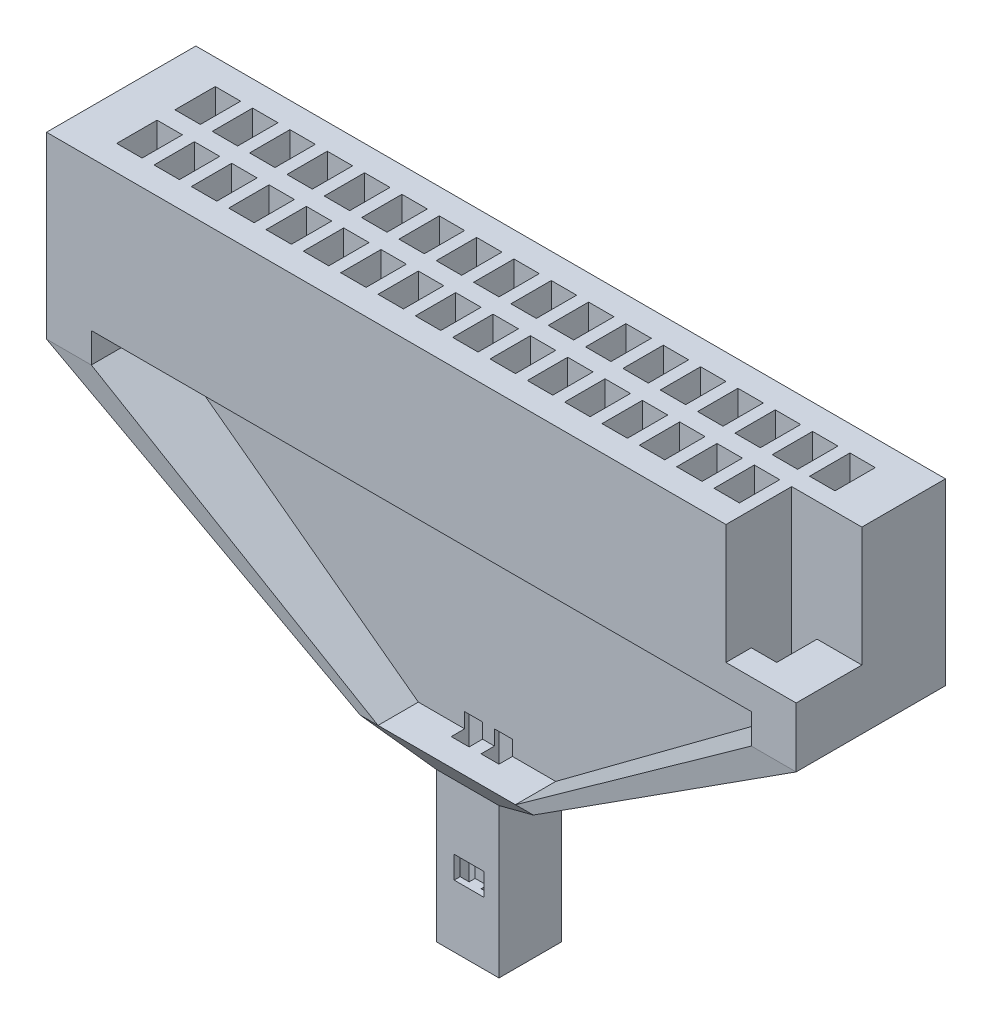
from build123d import *

# Parameters (mm, degrees)
MAIN_BLOCK_W        = 12.7508
MAIN_BLOCK_H        = 2.54
BOSS_EXTRUDE1_DEPTH = 2.54
TOP_HOLES_W         = 0.4318
TOP_HOLES_H         = 0.6858
CUT_EXTRUDE1_DEPTH  = 2.54
SKETCH8_W           = 0.762
SKETCH8_H           = 2.54
BOSS_EXTRUDE3_DEPTH = 0.508
SKETCH10_W          = 0.762
SKETCH10_H          = 2.54
BOSS_EXTRUDE2_DEPTH = 0.508
SKETCH7_W           = 0.3048
SKETCH7_H           = 1.77800034
SKETCH5_W           = 11.226700613
SKETCH5_H           = 0.3048
BOSS_EXTRUDE5_DEPTH = 0.508
SKETCH6_W           = 2.336782461
SKETCH6_H           = 0.3048
SKETCH12_W          = 2.9464
SKETCH12_H          = 1.77800034
SKETCH13_W          = 1.0668
SKETCH13_H          = 1.0668
SKETCH13_3_W        = 1.0668
SKETCH13_3_H        = 1.0668
BOSS_EXTRUDE6_DEPTH = 2.54
SKETCH14_W          = 0.3048
SKETCH14_H          = 0.3048
CUT_EXTRUDE2_DEPTH  = 3.302
SKETCH15_W          = 0.508
SKETCH15_H          = 0.381
CUT_EXTRUDE3_DEPTH  = 0.2032
SKETCH16_W          = 0.508
SKETCH16_H          = 0.381
CUT_EXTRUDE4_DEPTH  = 0.2032
SKETCH17_W          = 1.1938
SKETCH17_H          = 1.1176
CUT_EXTRUDE5_DEPTH  = 2.032


with BuildPart() as part:
    # main_block → Boss-Extrude1 (new body)
    with BuildSketch(Plane(origin=(0, 0, 0), x_dir=(1, 0, 0), z_dir=(0, 1, 0))):
        with Locations((0.756592766, -0.05080017)):
            Rectangle(MAIN_BLOCK_W, MAIN_BLOCK_H)
    extrude(amount=-BOSS_EXTRUDE1_DEPTH)

    # top_holes → Cut-Extrude1 (cut)
    with BuildSketch(Plane(origin=(0, 0, 0), x_dir=(1, 0, 0), z_dir=(0, 1, 0))):
        with Locations((6.154092766, 0.44449983)):
            Rectangle(TOP_HOLES_W, TOP_HOLES_H)
        with Locations((5.519098613, 0.44449983)):
            Rectangle(TOP_HOLES_W, TOP_HOLES_H)
        with Locations((4.884104459, 0.44449983)):
            Rectangle(TOP_HOLES_W, TOP_HOLES_H)
        with Locations((4.249110305, 0.44449983)):
            Rectangle(TOP_HOLES_W, TOP_HOLES_H)
        with Locations((3.614116151, 0.44449983)):
            Rectangle(TOP_HOLES_W, TOP_HOLES_H)
        with Locations((2.979121998, 0.44449983)):
            Rectangle(TOP_HOLES_W, TOP_HOLES_H)
        with Locations((2.344127844, 0.44449983)):
            Rectangle(TOP_HOLES_W, TOP_HOLES_H)
        with Locations((1.70913369, 0.44449983)):
            Rectangle(TOP_HOLES_W, TOP_HOLES_H)
        with Locations((1.074139537, 0.44449983)):
            Rectangle(TOP_HOLES_W, TOP_HOLES_H)
        with Locations((0.439145383, 0.44449983)):
            Rectangle(TOP_HOLES_W, TOP_HOLES_H)
        with Locations((-0.195848771, 0.44449983)):
            Rectangle(TOP_HOLES_W, TOP_HOLES_H)
        with Locations((-0.830842925, 0.44449983)):
            Rectangle(TOP_HOLES_W, TOP_HOLES_H)
        with Locations((-1.465837078, 0.44449983)):
            Rectangle(TOP_HOLES_W, TOP_HOLES_H)
        with Locations((-2.100831232, 0.44449983)):
            Rectangle(TOP_HOLES_W, TOP_HOLES_H)
        with Locations((-2.735825386, 0.44449983)):
            Rectangle(TOP_HOLES_W, TOP_HOLES_H)
        with Locations((-3.370819539, 0.44449983)):
            Rectangle(TOP_HOLES_W, TOP_HOLES_H)
        with Locations((-4.005813693, 0.44449983)):
            Rectangle(TOP_HOLES_W, TOP_HOLES_H)
        with Locations((-4.640807847, 0.44449983)):
            Rectangle(TOP_HOLES_W, TOP_HOLES_H)
        with Locations((5.519098613, -0.54610017)):
            Rectangle(TOP_HOLES_W, TOP_HOLES_H)
        with Locations((4.884104459, -0.54610017)):
            Rectangle(TOP_HOLES_W, TOP_HOLES_H)
        with Locations((4.249110305, -0.54610017)):
            Rectangle(TOP_HOLES_W, TOP_HOLES_H)
        with Locations((3.614116151, -0.54610017)):
            Rectangle(TOP_HOLES_W, TOP_HOLES_H)
        with Locations((2.979121998, -0.54610017)):
            Rectangle(TOP_HOLES_W, TOP_HOLES_H)
        with Locations((2.344127844, -0.54610017)):
            Rectangle(TOP_HOLES_W, TOP_HOLES_H)
        with Locations((1.70913369, -0.54610017)):
            Rectangle(TOP_HOLES_W, TOP_HOLES_H)
        with Locations((1.074139537, -0.54610017)):
            Rectangle(TOP_HOLES_W, TOP_HOLES_H)
        with Locations((0.439145383, -0.54610017)):
            Rectangle(TOP_HOLES_W, TOP_HOLES_H)
        with Locations((-0.195848771, -0.54610017)):
            Rectangle(TOP_HOLES_W, TOP_HOLES_H)
        with Locations((-0.830842925, -0.54610017)):
            Rectangle(TOP_HOLES_W, TOP_HOLES_H)
        with Locations((-1.465837078, -0.54610017)):
            Rectangle(TOP_HOLES_W, TOP_HOLES_H)
        with Locations((-2.100831232, -0.54610017)):
            Rectangle(TOP_HOLES_W, TOP_HOLES_H)
        with Locations((-2.735825386, -0.54610017)):
            Rectangle(TOP_HOLES_W, TOP_HOLES_H)
        with Locations((-3.370819539, -0.54610017)):
            Rectangle(TOP_HOLES_W, TOP_HOLES_H)
        with Locations((-4.005813693, -0.54610017)):
            Rectangle(TOP_HOLES_W, TOP_HOLES_H)
        with Locations((-4.640807847, -0.54610017)):
            Rectangle(TOP_HOLES_W, TOP_HOLES_H)
        with Locations((6.154092766, -0.54610017)):
            Rectangle(TOP_HOLES_W, TOP_HOLES_H)
    extrude(amount=-CUT_EXTRUDE1_DEPTH, mode=Mode.SUBTRACT)

    # Sketch8 → Boss-Extrude3 (add)
    with BuildSketch(Plane.XZ.offset(2.54)):
        with Locations((-5.237707847, 0.05080017)):
            Rectangle(SKETCH8_W, SKETCH8_H)
    extrude(amount=BOSS_EXTRUDE3_DEPTH)

    # Sketch10 → Boss-Extrude2 (add)
    with BuildSketch(Plane.XZ.offset(2.54)):
        with Locations((6.750992766, 0.05080017)):
            Rectangle(SKETCH10_W, SKETCH10_H)
    extrude(amount=BOSS_EXTRUDE2_DEPTH)

    # Sketch9 → section 0 of loft4
    with BuildSketch(Plane(origin=(0, -6.35, 0), x_dir=(1, 0, 0), z_dir=(0, 1, 0)), mode=Mode.PRIVATE) as loft4_s0:
        Polygon((1.92503369, -0.88900017), (1.924934303, 0.88900017), (2.229734303, 0.889017208), (2.22983369, -0.888983133), align=None)
    # loft up to a face of the part (loft4)
    loft([loft4_s0.sketch, part.faces().sort_by_distance((6.750992766, -3.048, 0.05080017))[0]])

    # Sketch7 → section 0 of loft14
    with BuildSketch(Plane(origin=(0, -6.35, 0), x_dir=(1, 0, 0), z_dir=(0, 1, 0)), mode=Mode.PRIVATE) as loft14_s0:
        with Locations((-0.564148771, 0)):
            Rectangle(SKETCH7_W, SKETCH7_H)
    # loft up to a face of the part (loft14)
    loft([loft14_s0.sketch, part.faces().sort_by_distance((-5.237707847, -3.048, 0.05080017))[0]])

    # Sketch5 → Boss-Extrude5 (add)
    with BuildSketch(Plane.XZ.offset(2.54)):
        with Locations((0.75664246, 0.05080017)):
            Rectangle(SKETCH5_W, SKETCH5_H)
    extrude(amount=BOSS_EXTRUDE5_DEPTH)

    # Sketch6 → section 1 of loft15
    with BuildSketch(Plane(origin=(0, -6.35, 0), x_dir=(1, 0, 0), z_dir=(0, 1, 0)), mode=Mode.PRIVATE) as loft15_s1:
        with Locations((0.756642459, -0.05080017)):
            Rectangle(SKETCH6_W, SKETCH6_H)
    # loft from a face of the part (loft15)
    loft([part.faces().sort_by_distance((0.75664246, -3.048, 0.05080017))[0], loft15_s1.sketch])

    # Sketch12 → Loft16 section 0
    with BuildSketch(Plane(origin=(0, -6.35, 0), x_dir=(1, 0, 0), z_dir=(0, 1, 0))):
        with Locations((0.756651229, 0)):
            Rectangle(SKETCH12_W, SKETCH12_H)
    # Sketch13 → Loft16 section 1
    with BuildSketch(Plane(origin=(0, -6.858, 0), x_dir=(1, 0, 0), z_dir=(0, 1, 0))):
        with Locations((0.756592766, 0)):
            Rectangle(SKETCH13_W, SKETCH13_H)
    loft()

    # Sketch13_3 → Boss-Extrude6 (add)
    with BuildSketch(Plane(origin=(0, -6.858, 0), x_dir=(1, 0, 0), z_dir=(0, 1, 0))):
        with Locations((0.756592766, 0)):
            Rectangle(SKETCH13_3_W, SKETCH13_3_H)
    extrude(amount=-BOSS_EXTRUDE6_DEPTH)

    # Sketch14 → Cut-Extrude2 (cut)
    with BuildSketch(Plane.XZ.offset(9.398)):
        with Locations((0.527992766, -0.2286)):
            Rectangle(SKETCH14_W, SKETCH14_H)
        with Locations((1.035992766, -0.2286)):
            Rectangle(SKETCH14_W, SKETCH14_H)
        with Locations((1.035992766, 0.2794)):
            Rectangle(SKETCH14_W, SKETCH14_H)
        with Locations((0.527992766, 0.2794)):
            Rectangle(SKETCH14_W, SKETCH14_H)
    extrude(amount=-CUT_EXTRUDE2_DEPTH, mode=Mode.SUBTRACT)

    # Sketch15 → Cut-Extrude3 (cut)
    with BuildSketch(Plane.XY.offset(0.5334)):
        with Locations((0.781992766, -8.146813232)):
            Rectangle(SKETCH15_W, SKETCH15_H)
    extrude(amount=-CUT_EXTRUDE3_DEPTH, mode=Mode.SUBTRACT)

    # Sketch16 → Cut-Extrude4 (cut)
    with BuildSketch(Plane(origin=(0, 0, -0.5334), x_dir=(-1, 0, 0), z_dir=(0, 0, -1))):
        with Locations((-0.781992766, -8.146813232)):
            Rectangle(SKETCH16_W, SKETCH16_H)
    extrude(amount=-CUT_EXTRUDE4_DEPTH, mode=Mode.SUBTRACT)

    # Sketch17 → Cut-Extrude5 (cut)
    with BuildSketch(Plane(origin=(0, 0, 0), x_dir=(1, 0, 0), z_dir=(0, 1, 0))):
        with Locations((6.535092766, -0.76200017)):
            Rectangle(SKETCH17_W, SKETCH17_H)
    extrude(amount=-CUT_EXTRUDE5_DEPTH, mode=Mode.SUBTRACT)


solid = part.part
